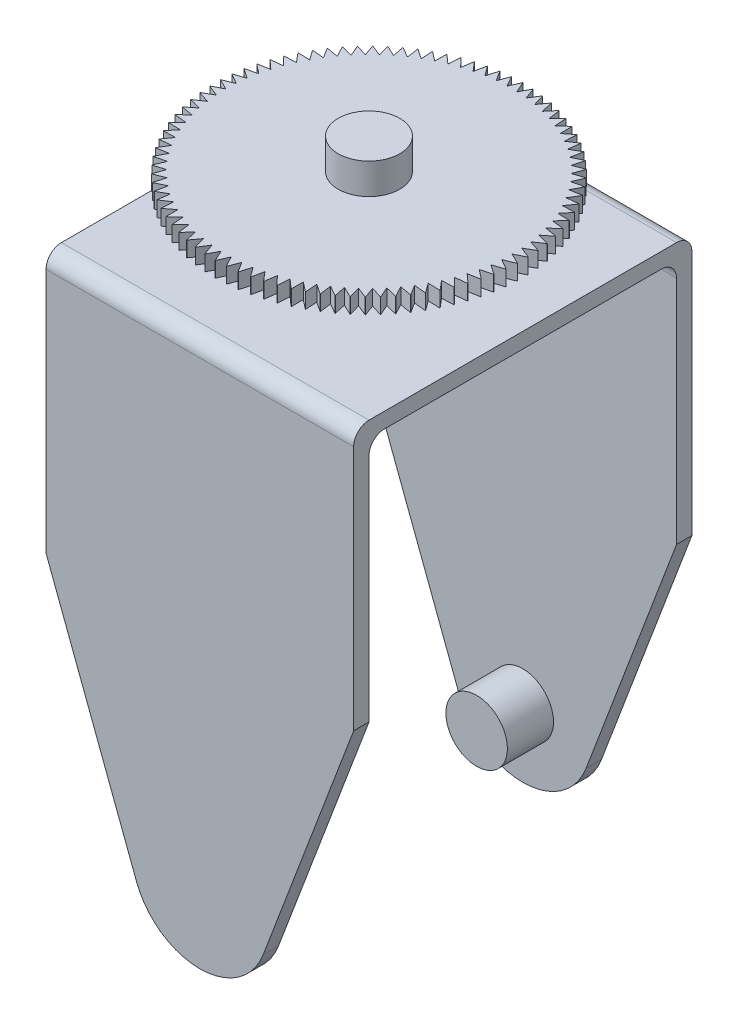
from build123d import *

# Parameters (mm, degrees)
BOSS_EXTRUDE1_DEPTH = 5
SKETCH4_R           = 10
BOSS_EXTRUDE2_DEPTH = 15
SKETCH5_W           = 100
SKETCH5_H           = 5
BOSS_EXTRUDE3_DEPTH = 55
FILLET1_R           = 5
SKETCH6_R           = 12.5
BOSS_EXTRUDE4_DEPTH = 5
SKETCH7_R           = 10
BOSS_EXTRUDE5_DEPTH = 5
SKETCH8_R           = 12.5
BOSS_EXTRUDE6_DEPTH = 5
BOSS_EXTRUDE7_DEPTH = 5
SKETCH10_R          = 10
BOSS_EXTRUDE8_DEPTH = 10


with BuildPart() as part:
    # Sketch3 → Boss-Extrude1 (new body)
    with BuildSketch(Plane.XY):
        with BuildLine():
            Line((-50, 150), (50, 150))
            Line((50, 150), (50, 70))
            Line((50, 70), (20.577059051, -7.783613608))
            ThreePointArc((20.577059051, -7.783613608), (0, -22), (-20.577059051, -7.783613608))
            Line((-20.577059051, -7.783613608), (-50, 70))
            Line((-50, 70), (-50, 150))
        make_face()
    extrude(amount=BOSS_EXTRUDE1_DEPTH)

    # Sketch4 → Boss-Extrude2 (add)
    with BuildSketch(Plane.XY.offset(5)):
        Circle(SKETCH4_R)
    extrude(amount=BOSS_EXTRUDE2_DEPTH)

    # Sketch5 → Boss-Extrude3 (add)
    with BuildSketch(Plane(origin=(0, 0, 0), x_dir=(-1, 0, 0), z_dir=(0, 0, -1))):
        with Locations((0, 152.5)):
            Rectangle(SKETCH5_W, SKETCH5_H)
    extrude(amount=-BOSS_EXTRUDE3_DEPTH)

    # Mirror1: part across plane


with BuildPart() as part_1:
    add(part.part)
    add(part.part.mirror(Plane.XY.offset(55)))

    # Fillet1
    fillet1_edges = [part_1.edges().sort_by_distance(p)[0] for p in [
        (0, 150, 5),
        (0, 155, 0),
        (0, 150, 105),
        (0, 155, 110),
    ]]
    fillet(fillet1_edges, radius=FILLET1_R)

    # Sketch6 → Boss-Extrude4 (add)
    with BuildSketch(Plane(origin=(0, 155, 0), x_dir=(1, 0, 0), z_dir=(0, 1, 0))):
        with Locations((0, -55)):
            Circle(SKETCH6_R)
    extrude(amount=BOSS_EXTRUDE4_DEPTH)

    # Sketch7 → Boss-Extrude5 (add)
    with BuildSketch(Plane(origin=(0, 160, 0), x_dir=(1, 0, 0), z_dir=(0, 1, 0))):
        with Locations((0, -55)):
            Circle(SKETCH7_R)
    extrude(amount=BOSS_EXTRUDE5_DEPTH)

    # Sketch8 → Boss-Extrude6 (add)
    with BuildSketch(Plane(origin=(0, 165, 0), x_dir=(1, 0, 0), z_dir=(0, 1, 0))):
        with Locations((0, -55)):
            Circle(SKETCH8_R)
    extrude(amount=BOSS_EXTRUDE6_DEPTH)

    # Sketch9 → Boss-Extrude7 (add)
    with BuildSketch(Plane(origin=(0, 170, 0), x_dir=(1, 0, 0), z_dir=(0, 1, 0))):
        with BuildLine():
            Line((1.592913605, -8.533590821), (0, -5))
            ThreePointArc((0, -5), (-0.03195169, -5.000010209), (-0.063903368, -5.000040836))
            Line((-0.063903368, -5.000040836), (-1.652299505, -8.535664623))
            Line((-1.652299505, -8.535664623), (-3.487823687, -5.121797487))
            ThreePointArc((-3.487823687, -5.121797487), (-3.519696833, -5.124036509), (-3.551568541, -5.126295898))
            Line((-3.551568541, -5.126295898), (-4.889462777, -8.764107995))
            Line((-4.889462777, -8.764107995), (-6.958655048, -5.486596563))
            ThreePointArc((-6.958655048, -5.486596563), (-6.990294366, -5.491053489), (-7.021930829, -5.495530632))
            Line((-7.021930829, -5.495530632), (-8.102805078, -9.217807986))
            Line((-8.102805078, -9.217807986), (-10.395584541, -6.092619963))
            ThreePointArc((-10.395584541, -6.092619963), (-10.426835888, -6.099273079), (-10.458082976, -6.105946165))
            Line((-10.458082976, -6.105946165), (-11.276671327, -9.894554215))
            Line((-11.276671327, -9.894554215), (-13.781867791, -6.936915203))
            ThreePointArc((-13.781867791, -6.936915203), (-13.812578913, -6.945732096), (-13.843284395, -6.954568613))
            Line((-13.843284395, -6.954568613), (-14.395598767, -10.791049641))
            Line((-14.395598767, -10.791049641), (-17.101007166, -8.015368961))
            ThreePointArc((-17.101007166, -8.015368961), (-17.131028442, -8.026306676), (-17.161042723, -8.037263573))
            Line((-17.161042723, -8.037263573), (-17.444392297, -11.90292663))
            Line((-17.444392297, -11.90292663), (-20.336832154, -9.322727118))
            ThreePointArc((-20.336832154, -9.322727118), (-20.366017323, -9.335732368), (-20.395194176, -9.348756265))
            Line((-20.395194176, -9.348756265), (-20.408198501, -13.224768228))
            Line((-20.408198501, -13.224768228), (-23.473578139, -10.852620357))
            ThreePointArc((-23.473578139, -10.852620357), (-23.501785015, -10.867629781), (-23.529982293, -10.882657227))
            Line((-23.529982293, -10.882657227), (-23.272578014, -14.750134555))
            Line((-23.272578014, -14.750134555), (-26.495963212, -12.597595192))
            ThreePointArc((-26.495963212, -12.597595192), (-26.523054372, -12.614535666), (-26.550134701, -12.631493449))
            Line((-26.550134701, -12.631493449), (-26.023575865, -16.471594182))
            Line((-26.023575865, -16.471594182), (-29.389262615, -14.549150281))
            ThreePointArc((-29.389262615, -14.549150281), (-29.415106074, -14.567939273), (-29.440937522, -14.586744776))
            Line((-29.440937522, -14.586744776), (-28.647789471, -18.380760329))
            Line((-28.647789471, -18.380760329), (-32.139380484, -16.697777844))
            ThreePointArc((-32.139380484, -16.697777844), (-32.163850337, -16.718323815), (-32.188307055, -16.73888542))
            Line((-32.188307055, -16.73888542), (-31.132433927, -20.46833173))
            Line((-31.132433927, -20.46833173), (-34.732918523, -19.033009983))
            ThreePointArc((-34.732918523, -19.033009983), (-34.755895554, -19.055212836), (-34.778858391, -19.077430368))
            Line((-34.778858391, -19.077430368), (-33.465404293, -22.724137948))
            Line((-33.465404293, -22.724137948), (-37.157241274, -21.543469682))
            ThreePointArc((-37.157241274, -21.543469682), (-37.178613541, -21.567221247), (-37.199970626, -21.590986464))
            Line((-37.199970626, -21.590986464), (-35.635334574, -25.137188922))
            Line((-35.635334574, -25.137188922), (-39.40053768, -24.216926234))
            ThreePointArc((-39.40053768, -24.216926234), (-39.42020106, -24.242110795), (-39.439848343, -24.267307916))
            Line((-39.439848343, -24.267307916), (-37.631653087, -27.695728509))
            Line((-37.631653087, -27.695728509), (-41.451878628, -27.040354827))
            ThreePointArc((-41.451878628, -27.040354826), (-41.469737323, -27.066849687), (-41.487579083, -27.093355955))
            Line((-41.487579083, -27.093355955), (-39.444633969, -30.387291763))
            Line((-39.444633969, -30.387291763), (-43.301270189, -30))
            ThreePointArc((-43.301270189, -30), (-43.317237193, -30.02767608), (-43.333186508, -30.055362358))
            Line((-43.333186508, -30.055362358), (-41.065444559, -33.198765657))
            Line((-41.065444559, -33.198765657), (-44.939702315, -33.081442661))
            ThreePointArc((-44.939702315, -33.081442661), (-44.953699838, -33.110165125), (-44.967679004, -33.138896529))
            Line((-44.967679004, -33.138896529), (-42.486188431, -36.116452973))
            Line((-42.486188431, -36.116452973), (-46.359192728, -36.269670329))
            ThreePointArc((-46.359192728, -36.269670329), (-46.371152577, -36.299299245), (-46.383093488, -36.328935798))
            Line((-46.383093488, -36.328935798), (-43.699943864, -39.126139033))
            Line((-43.699943864, -39.126139033), (-47.552825815, -39.549150281))
            ThreePointArc((-47.552825815, -39.549150281), (-47.562689721, -39.579541299), (-47.572534204, -39.609938615))
            Line((-47.572534204, -39.609938615), (-44.700797563, -42.213160947))
            Line((-44.700797563, -42.213160947), (-48.514786314, -42.90390522))
            ThreePointArc((-48.514786314, -42.90390522), (-48.522506221, -42.934910279), (-48.530206314, -42.965920264))
            Line((-48.530206314, -42.965920264), (-45.483873469, -45.362479056))
            Line((-45.483873469, -45.362479056), (-49.240387651, -46.317591117))
            ThreePointArc((-49.240387651, -46.317591117), (-49.245925949, -46.349059162), (-49.251444138, -46.38053074))
            Line((-49.251444138, -46.38053074), (-46.045356516, -48.558750198))
            Line((-46.045356516, -48.558750198), (-49.726094768, -49.773576837))
            ThreePointArc((-49.726094768, -49.773576837), (-49.729424476, -49.80535456), (-49.732733877, -49.837134404))
            Line((-49.732733876, -49.837134404), (-46.382511214, -51.786402461))
            Line((-46.382511214, -51.786402461), (-49.969541351, -53.255025165))
            ThreePointArc((-49.969541351, -53.255025165), (-49.970646246, -53.286957748), (-49.971730735, -53.31889103))
            Line((-49.971730735, -53.31889103), (-46.493694981, -55.029711049))
            Line((-46.493694981, -55.029711049), (-49.969541351, -56.744974835))
            ThreePointArc((-49.969541351, -56.744974835), (-49.96841605, -56.776906705), (-49.967270344, -56.80883785))
            Line((-49.967270344, -56.80883785), (-46.378366138, -58.272874888))
            Line((-46.378366138, -58.272874888), (-49.726094768, -60.226423163))
            ThreePointArc((-49.726094768, -60.226423163), (-49.722744754, -60.258198752), (-49.719374435, -60.289972193))
            Line((-49.719374435, -60.289972193), (-46.037086558, -61.500093609))
            Line((-46.037086558, -61.500093609), (-49.240387651, -63.682408883))
            ThreePointArc((-49.240387651, -63.682408883), (-49.234829244, -63.713873383), (-49.229250731, -63.745334324))
            Line((-49.229250731, -63.745334324), (-45.47151892, -64.695644527))
            Line((-45.47151892, -64.695644527), (-48.514786314, -67.09609478))
            ThreePointArc((-48.514786314, -67.09609478), (-48.507046594, -67.127094899), (-48.499287066, -67.158090066))
            Line((-48.499287066, -67.158090066), (-44.684418613, -67.84395924))
            Line((-44.684418613, -67.84395924), (-47.552825815, -70.450849719))
            ThreePointArc((-47.552825815, -70.450849719), (-47.54294249, -70.481234427), (-47.53303975, -70.511612814))
            Line((-47.53303975, -70.511612814), (-43.679620309, -70.929699475))
            Line((-43.679620309, -70.929699475), (-46.359192728, -73.730329671))
            ThreePointArc((-46.359192728, -73.730329671), (-46.347213949, -73.759950938), (-46.335216242, -73.789564544))
            Line((-46.335216242, -73.789564544), (-42.462019286, -73.937831815))
            Line((-42.462019286, -73.937831815), (-44.939702315, -76.91855734))
            ThreePointArc((-44.939702315, -76.91855734), (-44.92568644, -76.947270853), (-44.911652219, -76.975975405))
            Line((-44.911652219, -76.975975405), (-41.037547574, -76.853700942))
            Line((-41.037547574, -76.853700942), (-43.301270189, -80))
            ThreePointArc((-43.301270189, -80), (-43.285285503, -80.027665871), (-43.26928314, -80.055321522))
            Line((-43.26928314, -80.055321522), (-39.413145054, -79.663101034))
            Line((-39.413145054, -79.663101034), (-41.451878628, -82.959645174))
            ThreePointArc((-41.451878628, -82.959645174), (-41.434003005, -82.986128617), (-41.416110463, -83.012600631))
            Line((-41.416110463, -83.012600631), (-37.596725654, -82.352344978))
            Line((-37.596725654, -82.352344978), (-39.40053768, -85.783073766))
            ThreePointArc((-39.40053768, -85.783073766), (-39.380858211, -85.808245757), (-39.361162659, -85.833405166))
            Line((-39.361162659, -85.833405166), (-35.597138786, -84.908331046))
            Line((-35.597138786, -84.908331046), (-37.157241274, -88.456530318))
            ThreePointArc((-37.157241274, -88.456530318), (-37.135853833, -88.48026822), (-37.114451227, -88.50399245))
            Line((-37.114451227, -88.50399245), (-33.424126235, -87.318606732))
            Line((-33.424126235, -87.318606732), (-34.732918523, -90.966990017))
            ThreePointArc((-34.732918523, -90.966990017), (-34.709927308, -90.989178182), (-34.68692192, -91.011351651))
            Line((-34.68692192, -91.011351651), (-31.088274702, -89.571429415))
            Line((-31.088274702, -89.571429415), (-32.139380484, -93.302222156))
            ThreePointArc((-32.139380484, -93.302222156), (-32.114897507, -93.322752486), (-32.090401415, -93.343267167))
            Line((-32.090401415, -93.343267167), (-28.600964219, -91.655823568))
            Line((-28.600964219, -91.655823568), (-29.389262615, -95.450849719))
            ThreePointArc((-29.389262615, -95.450849719), (-29.363407153, -95.469622192), (-29.337539701, -95.488378139))
            Line((-29.337539701, -95.488378139), (-25.974312713, -93.561634234))
            Line((-25.974312713, -93.561634234), (-26.495963212, -97.402404808))
            ThreePointArc((-26.495963212, -97.402404808), (-26.468861231, -97.419327966), (-26.441748442, -97.436233802))
            Line((-26.441748442, -97.436233802), (-23.221116967, -95.279576494))
            Line((-23.221116967, -95.279576494), (-23.473578139, -99.147379643))
            ThreePointArc((-23.473578139, -99.147379643), (-23.445361678, -99.162371039), (-23.417135643, -99.177344401))
            Line((-23.417135643, -99.177344401), (-20.354790273, -96.801280706))
            Line((-20.354790273, -96.801280706), (-20.336832154, -100.677272882))
            ThreePointArc((-20.336832154, -100.677272882), (-20.30763868, -100.690259479), (-20.278436913, -100.703227418))
            Line((-20.278436913, -100.703227418), (-17.389297087, -98.11933328))
            Line((-17.389297087, -98.11933328), (-17.101007166, -101.984631039))
            ThreePointArc((-17.101007166, -101.984631039), (-17.070978907, -101.995549568), (-17.040943676, -102.006448905))
            Line((-17.040943676, -102.006448905), (-14.339084993, -99.227312797))
            Line((-14.339084993, -99.227312797), (-13.781867791, -103.063084797))
            ThreePointArc((-13.781867791, -103.063084797), (-13.751151041, -103.071882063), (-13.720428675, -103.080659698))
            Line((-13.720428675, -103.080659698), (-11.219014319, -100.119821292))
            Line((-11.219014319, -100.119821292), (-10.395584541, -103.907380037))
            ThreePointArc((-10.395584541, -103.907380037), (-10.364328949, -103.914013181), (-10.333069124, -103.92062635))
            Line((-10.333069124, -103.92062635), (-8.044285735, -100.792510553))
            Line((-8.044285735, -100.792510553), (-6.958655048, -104.513403437))
            ThreePointArc((-6.958655048, -104.513403437), (-6.927012888, -104.517840143), (-6.8953679, -104.522256628))
            Line((-6.8953679, -104.522256628), (-4.830366199, -101.242103305))
            Line((-4.830366199, -101.242103305), (-3.487823687, -104.878202513))
            ThreePointArc((-3.487823687, -104.878202513), (-3.455949117, -104.880421166), (-3.424073136, -104.88261945))
            Line((-3.424073136, -104.88261945), (-1.592913605, -101.466409179))
            Line((-1.592913605, -101.466409179), (0, -105))
            ThreePointArc((0, -105), (0.031951691, -104.999989791), (0.063903368, -104.999959164))
            Line((0.063903368, -104.999959164), (1.652299505, -101.464335377))
            Line((1.652299505, -101.464335377), (3.487823687, -104.878202513))
            ThreePointArc((3.487823687, -104.878202513), (3.519696833, -104.875963491), (3.551568541, -104.873704102))
            Line((3.551568541, -104.873704102), (4.889462777, -101.235892005))
            Line((4.889462777, -101.235892005), (6.958655048, -104.513403437))
            ThreePointArc((6.958655048, -104.513403437), (6.990294366, -104.508946511), (7.021930829, -104.504469368))
            Line((7.021930829, -104.504469368), (8.102805078, -100.782192014))
            Line((8.102805078, -100.782192014), (10.395584541, -103.907380037))
            ThreePointArc((10.395584541, -103.907380037), (10.426835888, -103.900726921), (10.458082977, -103.894053835))
            Line((10.458082977, -103.894053835), (11.276671327, -100.105445785))
            Line((11.276671327, -100.105445785), (13.781867791, -103.063084797))
            ThreePointArc((13.781867791, -103.063084797), (13.812578913, -103.054267904), (13.843284395, -103.045431387))
            Line((13.843284395, -103.045431387), (14.395598767, -99.208950359))
            Line((14.395598767, -99.208950359), (17.101007166, -101.984631039))
            ThreePointArc((17.101007166, -101.984631039), (17.131028442, -101.973693324), (17.161042723, -101.962736427))
            Line((17.161042723, -101.962736427), (17.444392297, -98.09707337))
            Line((17.444392297, -98.09707337), (20.336832154, -100.677272882))
            ThreePointArc((20.336832154, -100.677272882), (20.366017323, -100.664267632), (20.395194176, -100.651243735))
            Line((20.395194176, -100.651243735), (20.408198501, -96.775231772))
            Line((20.408198501, -96.775231772), (23.473578139, -99.147379643))
            ThreePointArc((23.473578139, -99.147379643), (23.501785015, -99.132370219), (23.529982293, -99.117342772))
            Line((23.529982293, -99.117342773), (23.272578014, -95.249865445))
            Line((23.272578014, -95.249865445), (26.495963212, -97.402404808))
            ThreePointArc((26.495963212, -97.402404808), (26.523054372, -97.385464334), (26.550134701, -97.368506551))
            Line((26.550134701, -97.368506551), (26.023575865, -93.528405818))
            Line((26.023575865, -93.528405818), (29.389262615, -95.450849719))
            ThreePointArc((29.389262615, -95.450849719), (29.415106075, -95.432060727), (29.440937522, -95.413255224))
            Line((29.440937522, -95.413255224), (28.647789471, -91.619239671))
            Line((28.647789471, -91.619239671), (32.139380484, -93.302222156))
            ThreePointArc((32.139380484, -93.302222156), (32.163850337, -93.281676185), (32.188307055, -93.26111458))
            Line((32.188307055, -93.26111458), (31.132433927, -89.53166827))
            Line((31.132433927, -89.53166827), (34.732918523, -90.966990017))
            ThreePointArc((34.732918523, -90.966990017), (34.755895554, -90.944787164), (34.778858392, -90.922569632))
            Line((34.778858392, -90.922569632), (33.465404293, -87.275862052))
            Line((33.465404293, -87.275862052), (37.157241274, -88.456530318))
            ThreePointArc((37.157241274, -88.456530318), (37.178613541, -88.432778753), (37.199970626, -88.409013536))
            Line((37.199970626, -88.409013536), (35.635334574, -84.862811078))
            Line((35.635334574, -84.862811078), (39.40053768, -85.783073766))
            ThreePointArc((39.40053768, -85.783073766), (39.42020106, -85.757889205), (39.439848343, -85.732692084))
            Line((39.439848343, -85.732692084), (37.631653087, -82.304271491))
            Line((37.631653087, -82.304271491), (41.451878628, -82.959645173))
            ThreePointArc((41.451878628, -82.959645173), (41.469737323, -82.933150313), (41.487579083, -82.906644045))
            Line((41.487579083, -82.906644045), (39.444633969, -79.612708237))
            Line((39.444633969, -79.612708237), (43.301270189, -80))
            ThreePointArc((43.301270189, -80), (43.317237193, -79.97232392), (43.333186508, -79.944637642))
            Line((43.333186508, -79.944637642), (41.065444559, -76.801234343))
            Line((41.065444559, -76.801234343), (44.939702315, -76.918557339))
            ThreePointArc((44.939702315, -76.918557339), (44.953699838, -76.889834875), (44.967679004, -76.861103471))
            Line((44.967679004, -76.861103471), (42.486188431, -73.883547027))
            Line((42.486188431, -73.883547027), (46.359192728, -73.730329671))
            ThreePointArc((46.359192728, -73.730329671), (46.371152577, -73.700700755), (46.383093488, -73.671064202))
            Line((46.383093488, -73.671064202), (43.699943864, -70.873860967))
            Line((43.699943864, -70.873860967), (47.552825815, -70.450849719))
            ThreePointArc((47.552825815, -70.450849719), (47.562689721, -70.4204587), (47.572534204, -70.390061385))
            Line((47.572534204, -70.390061385), (44.700797563, -67.786839053))
            Line((44.700797563, -67.786839053), (48.514786314, -67.09609478))
            ThreePointArc((48.514786314, -67.09609478), (48.522506221, -67.065089721), (48.530206314, -67.034079736))
            Line((48.530206314, -67.034079736), (45.483873469, -64.637520944))
            Line((45.483873469, -64.637520944), (49.240387651, -63.682408883))
            ThreePointArc((49.240387651, -63.682408883), (49.245925949, -63.650940838), (49.251444138, -63.61946926))
            Line((49.251444138, -63.61946926), (46.045356516, -61.441249802))
            Line((46.045356516, -61.441249802), (49.726094768, -60.226423163))
            ThreePointArc((49.726094768, -60.226423163), (49.729424476, -60.19464544), (49.732733877, -60.162865596))
            Line((49.732733877, -60.162865596), (46.382511215, -58.213597539))
            Line((46.382511215, -58.213597539), (49.969541351, -56.744974835))
            ThreePointArc((49.969541351, -56.744974835), (49.970646246, -56.713042252), (49.971730735, -56.68110897))
            Line((49.971730735, -56.68110897), (46.493694981, -54.970288951))
            Line((46.493694981, -54.970288951), (49.969541351, -53.255025165))
            ThreePointArc((49.969541351, -53.255025165), (49.96841605, -53.223093295), (49.967270344, -53.19116215))
            Line((49.967270344, -53.19116215), (46.378366139, -51.727125112))
            Line((46.378366139, -51.727125112), (49.726094768, -49.773576837))
            ThreePointArc((49.726094768, -49.773576837), (49.722744754, -49.741801248), (49.719374435, -49.710027807))
            Line((49.719374435, -49.710027807), (46.037086558, -48.499906391))
            Line((46.037086558, -48.499906391), (49.240387651, -46.317591117))
            ThreePointArc((49.240387651, -46.317591117), (49.234829244, -46.286126617), (49.229250731, -46.254665676))
            Line((49.229250731, -46.254665676), (45.47151892, -45.304355473))
            Line((45.47151892, -45.304355473), (48.514786314, -42.90390522))
            ThreePointArc((48.514786314, -42.90390522), (48.507046594, -42.872905101), (48.499287066, -42.841909934))
            Line((48.499287067, -42.841909934), (44.684418613, -42.15604076))
            Line((44.684418613, -42.15604076), (47.552825815, -39.549150281))
            ThreePointArc((47.552825815, -39.549150281), (47.54294249, -39.518765573), (47.53303975, -39.488387186))
            Line((47.53303975, -39.488387186), (43.679620309, -39.070300525))
            Line((43.679620309, -39.070300525), (46.359192728, -36.269670329))
            ThreePointArc((46.359192728, -36.269670329), (46.347213949, -36.240049062), (46.335216243, -36.210435456))
            Line((46.335216243, -36.210435456), (42.462019286, -36.062168185))
            Line((42.462019286, -36.062168185), (44.939702315, -33.08144266))
            ThreePointArc((44.939702315, -33.081442661), (44.92568644, -33.052729147), (44.911652219, -33.024024595))
            Line((44.911652219, -33.024024595), (41.037547574, -33.146299058))
            Line((41.037547574, -33.146299058), (43.301270189, -30))
            ThreePointArc((43.301270189, -30), (43.285285503, -29.972334129), (43.26928314, -29.944678478))
            Line((43.26928314, -29.944678478), (39.413145054, -30.336898966))
            Line((39.413145054, -30.336898966), (41.451878628, -27.040354826))
            ThreePointArc((41.451878628, -27.040354826), (41.434003005, -27.013871383), (41.416110463, -26.987399369))
            Line((41.416110463, -26.987399369), (37.596725654, -27.647655022))
            Line((37.596725654, -27.647655022), (39.40053768, -24.216926234))
            ThreePointArc((39.40053768, -24.216926234), (39.380858211, -24.191754243), (39.361162659, -24.166594834))
            Line((39.361162659, -24.166594834), (35.597138786, -25.091668954))
            Line((35.597138786, -25.091668954), (37.157241274, -21.543469682))
            ThreePointArc((37.157241274, -21.543469682), (37.135853833, -21.51973178), (37.114451227, -21.49600755))
            Line((37.114451227, -21.49600755), (33.424126236, -22.681393268))
            Line((33.424126236, -22.681393268), (34.732918523, -19.033009983))
            ThreePointArc((34.732918523, -19.033009983), (34.709927308, -19.010821818), (34.68692192, -18.988648349))
            Line((34.68692192, -18.988648349), (31.088274702, -20.428570585))
            Line((31.088274702, -20.428570585), (32.139380484, -16.697777844))
            ThreePointArc((32.139380484, -16.697777844), (32.114897507, -16.677247514), (32.090401415, -16.656732833))
            Line((32.090401415, -16.656732833), (28.600964219, -18.344176432))
            Line((28.600964219, -18.344176432), (29.389262615, -14.549150281))
            ThreePointArc((29.389262615, -14.549150281), (29.363407153, -14.530377808), (29.337539701, -14.511621861))
            Line((29.337539701, -14.511621861), (25.974312713, -16.438365766))
            Line((25.974312713, -16.438365766), (26.495963212, -12.597595192))
            ThreePointArc((26.495963212, -12.597595192), (26.468861231, -12.580672034), (26.441748442, -12.563766198))
            Line((26.441748442, -12.563766198), (23.221116967, -14.720423506))
            Line((23.221116967, -14.720423506), (23.473578139, -10.852620357))
            ThreePointArc((23.473578139, -10.852620357), (23.445361678, -10.837628961), (23.417135643, -10.822655599))
            Line((23.417135643, -10.822655599), (20.354790273, -13.198719294))
            Line((20.354790273, -13.198719294), (20.336832154, -9.322727118))
            ThreePointArc((20.336832154, -9.322727118), (20.30763868, -9.309740521), (20.278436913, -9.296772582))
            Line((20.278436913, -9.296772582), (17.389297087, -11.88066672))
            Line((17.389297087, -11.88066672), (17.101007166, -8.015368961))
            ThreePointArc((17.101007166, -8.015368961), (17.070978907, -8.004450432), (17.040943676, -7.993551095))
            Line((17.040943676, -7.993551095), (14.339084994, -10.772687203))
            Line((14.339084994, -10.772687203), (13.781867791, -6.936915203))
            ThreePointArc((13.781867791, -6.936915203), (13.751151041, -6.928117937), (13.720428675, -6.919340302))
            Line((13.720428675, -6.919340302), (11.219014319, -9.880178708))
            Line((11.219014319, -9.880178708), (10.395584541, -6.092619963))
            ThreePointArc((10.395584541, -6.092619963), (10.364328949, -6.085986819), (10.333069125, -6.07937365))
            Line((10.333069125, -6.07937365), (8.044285735, -9.207489447))
            Line((8.044285735, -9.207489447), (6.958655048, -5.486596563))
            ThreePointArc((6.958655048, -5.486596563), (6.927012888, -5.482159857), (6.8953679, -5.477743372))
            Line((6.8953679, -5.477743372), (4.830366199, -8.757896695))
            Line((4.830366199, -8.757896695), (3.487823687, -5.121797487))
            ThreePointArc((3.487823687, -5.121797487), (3.455949117, -5.119578834), (3.424073136, -5.11738055))
            Line((3.424073136, -5.11738055), (1.592913605, -8.533590821))
        make_face()
    extrude(amount=BOSS_EXTRUDE7_DEPTH)

    # Sketch10 → Boss-Extrude8 (add)
    with BuildSketch(Plane(origin=(0, 175, 0), x_dir=(1, 0, 0), z_dir=(0, 1, 0))):
        with Locations((0, -55)):
            Circle(SKETCH10_R)
    extrude(amount=BOSS_EXTRUDE8_DEPTH)


solid = part_1.part
